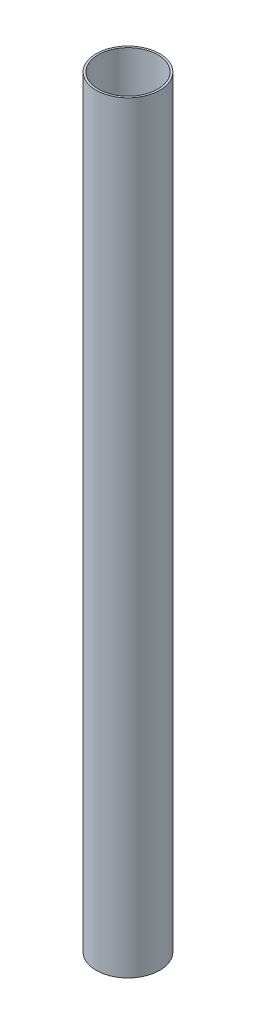
from build123d import *

# Parameters (mm, degrees)
SKETCH1_R           = 50.8
SKETCH1_R_2         = 47.625
BOSS_EXTRUDE1_DEPTH = 1219.2


with BuildPart() as part:
    # Sketch1 → Boss-Extrude1 (new body)
    with BuildSketch(Plane(origin=(0, 0, 0), x_dir=(1, 0, 0), z_dir=(0, 1, 0))):
        Circle(SKETCH1_R)
        Circle(SKETCH1_R_2, mode=Mode.SUBTRACT)
    extrude(amount=BOSS_EXTRUDE1_DEPTH)


solid = part.part
